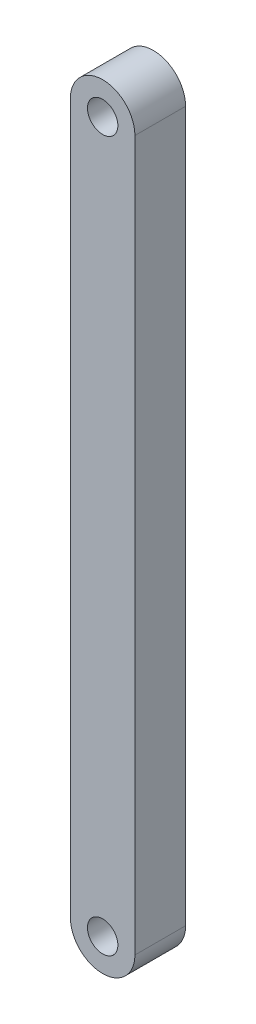
from build123d import *

# Parameters (mm, degrees)
EXTRUDE_3_DEPTH = 1


with BuildPart() as part:
    # 草图1 → 凸台-拉伸3 (new body)
    with BuildSketch(Plane.XY):
        with BuildLine():
            ThreePointArc((-0.3, 7), (0, 7.3), (0.3, 7))
            Line((0.3, 7), (0.636363636, 7))
            ThreePointArc((0.636363636, 7), (0, 7.636363636), (-0.636363636, 7))
            Line((-0.636363636, 7), (-0.3, 7))
        make_face()
        with BuildLine():
            Line((0.636363636, 7), (0.3, 7))
            ThreePointArc((0.3, 7), (0, 6.7), (-0.3, 7))
            Line((-0.3, 7), (-0.636363636, 7))
            ThreePointArc((-0.636363636, 7), (0, 6.363636364), (0.636363636, 7))
        make_face()
        with BuildLine():
            Line((0.636363636, -7), (0.636363636, 7))
            ThreePointArc((0.636363636, 7), (0, 6.363636364), (-0.636363636, 7))
            Line((-0.636363636, 7), (-0.636363636, -7))
            ThreePointArc((-0.636363636, -7), (0, -6.363636364), (0.636363636, -7))
        make_face()
        with BuildLine():
            ThreePointArc((-0.636363636, -7), (0, -7.636363636), (0.636363636, -7))
            Line((0.636363636, -7), (0.3, -7))
            ThreePointArc((0.3, -7), (0, -7.3), (-0.3, -7))
            Line((-0.3, -7), (-0.636363636, -7))
        make_face()
        with BuildLine():
            Line((0.3, -7), (0.636363636, -7))
            ThreePointArc((0.636363636, -7), (0, -6.363636364), (-0.636363636, -7))
            Line((-0.636363636, -7), (-0.3, -7))
            ThreePointArc((-0.3, -7), (0, -6.7), (0.3, -7))
        make_face()
    extrude(amount=EXTRUDE_3_DEPTH)


solid = part.part
